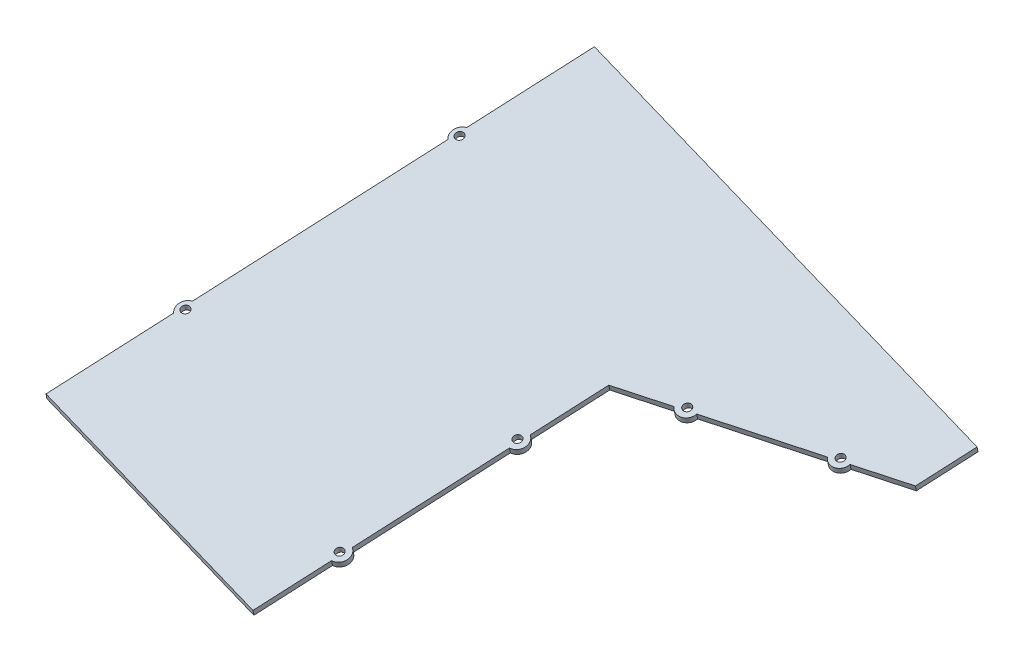
from build123d import *

# Parameters (mm, degrees)
BOSS_EXTRUDE1_DEPTH     = 3
CUT_EXTRUDE2_DEPTH      = 80
BOSS_EXTRUDE2_DEPTH     = 3
SKETCH6_R               = 4.999999998
BOSS_EXTRUDE3_DEPTH     = 3
SKETCH7_R               = 2.099999998
CUT_EXTRUDE8_DEPTH      = 103.727128927
CUT_EXTRUDE8_DEPTH_BACK = 93.470854005


with BuildPart() as part:
    # Sketch1 → Boss-Extrude1 (new body)
    with BuildSketch(Plane(origin=(349.089252495, 2874.058311474, 804.288278977), x_dir=(0.935705749, -0.202672232, 0.288753733), z_dir=(-0.118950757, -0.951829224, -0.282616075))):
        Polygon((-227.79105078, 209.509165447), (-94.070562084, 190.966487567), (-128.879732086, -60.059780262), (-262.600220782, -41.517102382), align=None)
    extrude(amount=-BOSS_EXTRUDE1_DEPTH)

    # Sketch3 → Cut-Extrude2 (cut)
    with BuildSketch(Plane(origin=(688.574610071, 446.833813903, 894.692140277), x_dir=(0.516756682, 0.537673014, -0.66623589), z_dir=(0.567103814, 0.368008283, 0.736860345))):
        Polygon((970.937778761, -219.886702224), (970.937778761, 845.245168422), (-1124.286512281, 775.631358808), (-1124.286512281, -289.500511838), align=None)
    extrude(amount=CUT_EXTRUDE2_DEPTH, mode=Mode.SUBTRACT)

    # Sketch4 → Boss-Extrude2 (add)
    with BuildSketch(Plane(origin=(357.380640452, 2859.715621096, 849.10358184), x_dir=(0.992857215, -0.11667261, -0.024940964), z_dir=(-0.118950757, -0.951829224, -0.282616075))):
        Polygon((-128.234790436, -58.388271423), (-111.076725557, -145.727367265), (1.37386057, -123.636064008), (-4.113952819, -95.701639995), align=None)
    extrude(amount=-BOSS_EXTRUDE2_DEPTH)

    # Sketch6 → Boss-Extrude3 (add)
    with BuildSketch(Plane(origin=(357.737492723, 2862.571108769, 849.951430064), x_dir=(0.992900155, -0.114030405, -0.033857781), z_dir=(0.118950757, 0.951829224, 0.282616075))):
        with Locations((-252.279251986, 111.451515819)):
            Circle(SKETCH6_R)
        with Locations((-137.453856598, 19.622629821)):
            Circle(SKETCH6_R)
        with Locations((-154.05088047, -60.894440309)):
            Circle(SKETCH6_R)
        with Locations((-96.98907211, 70.058139701)):
            Circle(SKETCH6_R)
        with Locations((-34.757829169, 88.136852409)):
            Circle(SKETCH6_R)
        with Locations((-277.861066086, -12.653428287)):
            Circle(SKETCH6_R)
    extrude(amount=-BOSS_EXTRUDE3_DEPTH)

    # Sketch7 → Cut-Extrude8 (cut, two sides)
    with BuildSketch(Plane(origin=(357.737492723, 2862.571108769, 849.951430064), x_dir=(0.992900155, -0.114030405, -0.033857781), z_dir=(0.118950757, 0.951829224, 0.282616075))) as cut_extrude8_sk:
        with Locations((-253.258660999, 111.653401888)):
            Circle(SKETCH7_R)
        with Locations((-278.8404751, -12.451542218)):
            Circle(SKETCH7_R)
        with Locations((-34.757829169, 88.136852409)):
            Circle(SKETCH7_R)
        with Locations((-96.98907211, 70.058139701)):
            Circle(SKETCH7_R)
        with Locations((-137.453856598, 19.622629821)):
            Circle(SKETCH7_R)
        with Locations((-154.05088047, -60.894440309)):
            Circle(SKETCH7_R)
    extrude(amount=CUT_EXTRUDE8_DEPTH, mode=Mode.SUBTRACT)
    extrude(cut_extrude8_sk.sketch, amount=-CUT_EXTRUDE8_DEPTH_BACK, mode=Mode.SUBTRACT)


solid = part.part
